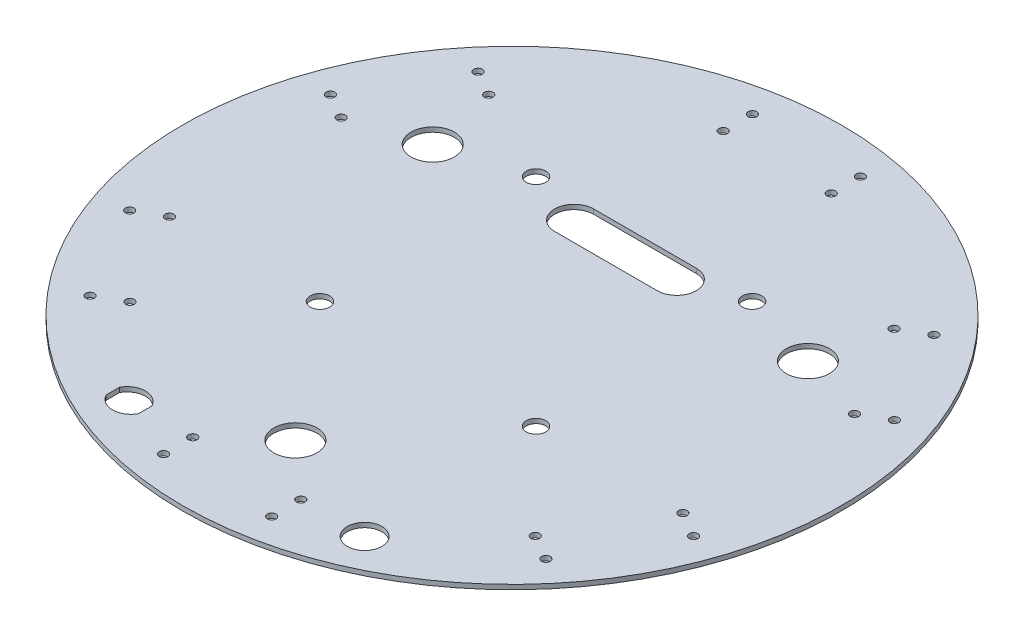
from build123d import *

# Parameters (mm, degrees)
SKETCH1_R           = 152.5
SKETCH1_R_2         = 2
SKETCH1_R_3         = 10
SKETCH1_R_4         = 8
SKETCH1_R_5         = 4.5
BOSS_EXTRUDE1_DEPTH = 2.15


with BuildPart() as part:
    # Sketch1 → Boss-Extrude1 (new body)
    with BuildSketch(Plane(origin=(0, 0, 0), x_dir=(1, 0, 0), z_dir=(0, 1, 0))):
        Circle(SKETCH1_R)
        with Locations((-25, -136.224997706)):
            Circle(SKETCH1_R_2, mode=Mode.SUBTRACT)
        with Locations((-25, -122.724997706)):
            Circle(SKETCH1_R_2, mode=Mode.SUBTRACT)
        with Locations((25, -136.224997706)):
            Circle(SKETCH1_R_2, mode=Mode.SUBTRACT)
        with Locations((25, -122.724997706)):
            Circle(SKETCH1_R_2, mode=Mode.SUBTRACT)
        with Locations((-118.782965693, -39.711863758)):
            Circle(SKETCH1_R_2, mode=Mode.SUBTRACT)
        with Locations((-130.474308644, -46.461863758)):
            Circle(SKETCH1_R_2, mode=Mode.SUBTRACT)
        with Locations((-93.782965693, -83.013133948)):
            Circle(SKETCH1_R_2, mode=Mode.SUBTRACT)
        with Locations((-105.474308644, -89.763133948)):
            Circle(SKETCH1_R_2, mode=Mode.SUBTRACT)
        with Locations((-93.782965693, 83.013133948)):
            Circle(SKETCH1_R_2, mode=Mode.SUBTRACT)
        with Locations((-105.474308644, 89.763133948)):
            Circle(SKETCH1_R_2, mode=Mode.SUBTRACT)
        with Locations((-118.782965693, 39.711863758)):
            Circle(SKETCH1_R_2, mode=Mode.SUBTRACT)
        with Locations((-130.474308644, 46.461863758)):
            Circle(SKETCH1_R_2, mode=Mode.SUBTRACT)
        with Locations((25, 122.724997706)):
            Circle(SKETCH1_R_2, mode=Mode.SUBTRACT)
        with Locations((25, 136.224997706)):
            Circle(SKETCH1_R_2, mode=Mode.SUBTRACT)
        with Locations((-25, 122.724997706)):
            Circle(SKETCH1_R_2, mode=Mode.SUBTRACT)
        with Locations((-25, 136.224997706)):
            Circle(SKETCH1_R_2, mode=Mode.SUBTRACT)
        with Locations((118.782965693, 39.711863758)):
            Circle(SKETCH1_R_2, mode=Mode.SUBTRACT)
        with Locations((130.474308644, 46.461863758)):
            Circle(SKETCH1_R_2, mode=Mode.SUBTRACT)
        with Locations((93.782965693, 83.013133948)):
            Circle(SKETCH1_R_2, mode=Mode.SUBTRACT)
        with Locations((105.474308644, 89.763133948)):
            Circle(SKETCH1_R_2, mode=Mode.SUBTRACT)
        with Locations((93.782965693, -83.013133948)):
            Circle(SKETCH1_R_2, mode=Mode.SUBTRACT)
        with Locations((105.474308644, -89.763133948)):
            Circle(SKETCH1_R_2, mode=Mode.SUBTRACT)
        with Locations((118.782965693, -39.711863758)):
            Circle(SKETCH1_R_2, mode=Mode.SUBTRACT)
        with Locations((130.474308644, -46.461863758)):
            Circle(SKETCH1_R_2, mode=Mode.SUBTRACT)
        with Locations((0, -100.224997706)):
            Circle(SKETCH1_R_3, mode=Mode.SUBTRACT)
        with Locations((-86.797394108, 50.112498853)):
            Circle(SKETCH1_R_3, mode=Mode.SUBTRACT)
        with Locations((86.797394108, 50.112498853)):
            Circle(SKETCH1_R_3, mode=Mode.SUBTRACT)
        with Locations((54.5, -122.724997706)):
            Circle(SKETCH1_R_4, mode=Mode.SUBTRACT)
        with Locations((-50, 61.116126736)):
            Circle(SKETCH1_R_5, mode=Mode.SUBTRACT)
        with Locations((-50, -38.883873264)):
            Circle(SKETCH1_R_5, mode=Mode.SUBTRACT)
        with Locations((50, -38.883873264)):
            Circle(SKETCH1_R_5, mode=Mode.SUBTRACT)
        with Locations((50, 61.116126736)):
            Circle(SKETCH1_R_5, mode=Mode.SUBTRACT)
        with BuildLine():
            Line((-23.75, 61.525), (23.75, 61.525))
            ThreePointArc((23.75, 61.525), (32.775, 52.5), (23.75, 43.475))
            Line((23.75, 43.475), (-23.75, 43.475))
            ThreePointArc((-23.75, 43.475), (-32.775, 52.5), (-23.75, 61.525))
        make_face(mode=Mode.SUBTRACT)
        with BuildLine():
            Line((-62, -125.799997706), (-62, -119.649997706))
            ThreePointArc((-62, -119.649997706), (-54.5, -115.126660151), (-47, -119.649997706))
            Line((-47, -119.649997706), (-47, -125.799997706))
            ThreePointArc((-47, -125.799997706), (-54.5, -130.323335261), (-62, -125.799997706))
        make_face(mode=Mode.SUBTRACT)
    extrude(amount=BOSS_EXTRUDE1_DEPTH)


solid = part.part
